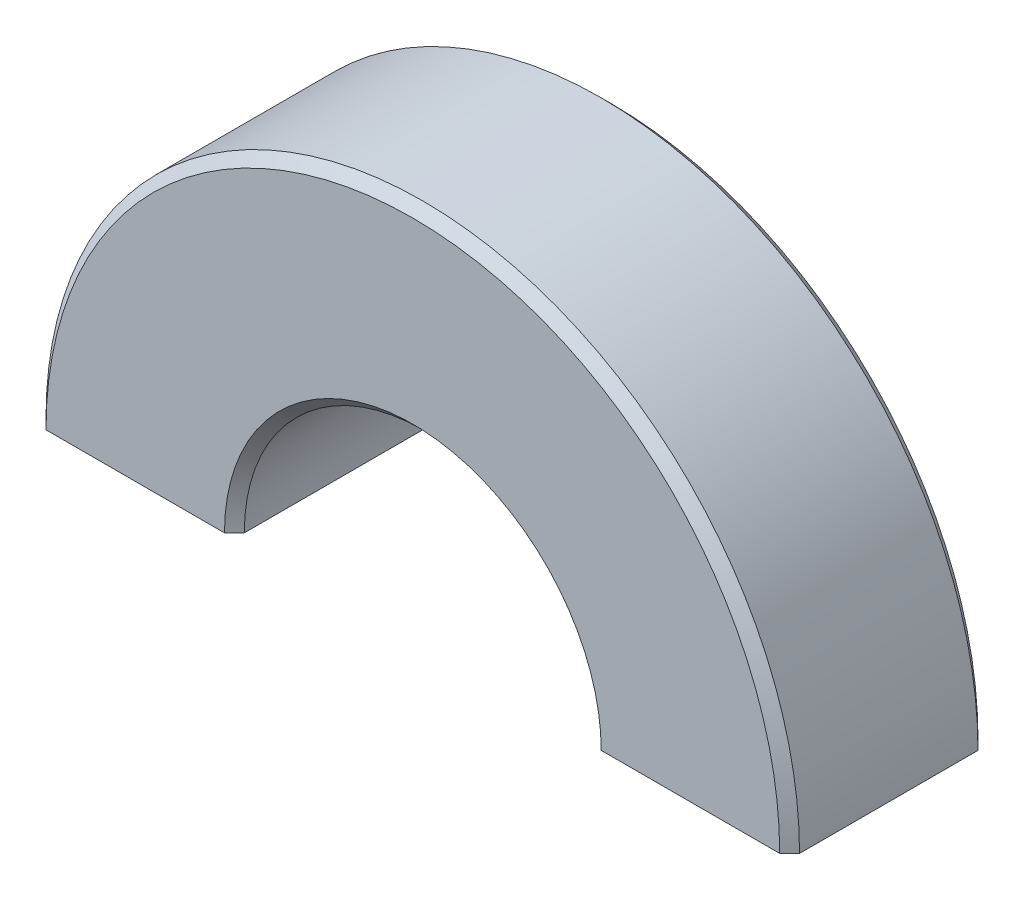
from build123d import *

# Parameters (mm, degrees)
BOSS_EXTRUDE1_DEPTH = 10
CHAMFER1_SIZE       = 0.5


with BuildPart() as part:
    # Sketch1 → Boss-Extrude1 (new body)
    with BuildSketch(Plane.XY):
        with BuildLine():
            Line((-9, 0), (-19, 0))
            ThreePointArc((-19, 0), (0, 19), (19, 0))
            Line((19, 0), (9, 0))
            ThreePointArc((9, 0), (0, 9), (-9, 0))
        make_face()
    extrude(amount=BOSS_EXTRUDE1_DEPTH)

    # Chamfer1
    chamfer1_edges = [part.edges().sort_by_distance(p)[0] for p in [
        (0, 19, 10),
        (0, 9, 10),
        (0, 19, 0),
        (0, 9, 0),
    ]]
    chamfer(chamfer1_edges, length=CHAMFER1_SIZE)


solid = part.part
